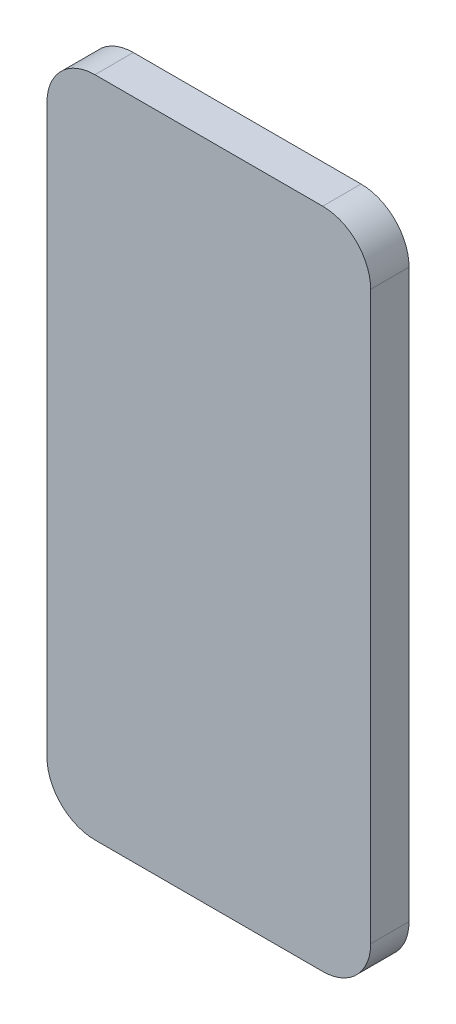
from build123d import *

# Parameters (mm, degrees)
BOSS_EXTRUDE1_DEPTH = 7.62


with BuildPart() as part:
    # Sketch1 → Boss-Extrude1 (new body)
    with BuildSketch(Plane.XY):
        with BuildLine():
            Line((-22.606, -65.786), (22.606, -65.786))
            ThreePointArc((22.606, -65.786), (29.341192091, -62.996192091), (32.131, -56.261))
            Line((32.131, -56.261), (32.131, 56.261))
            ThreePointArc((32.131, 56.261), (29.341192091, 62.996192091), (22.606, 65.786))
            Line((22.606, 65.786), (-22.606, 65.786))
            ThreePointArc((-22.606, 65.786), (-29.341192091, 62.996192091), (-32.131, 56.261))
            Line((-32.131, 56.261), (-32.131, -56.261))
            ThreePointArc((-32.131, -56.261), (-29.341192091, -62.996192091), (-22.606, -65.786))
        make_face()
    extrude(amount=BOSS_EXTRUDE1_DEPTH)


solid = part.part
